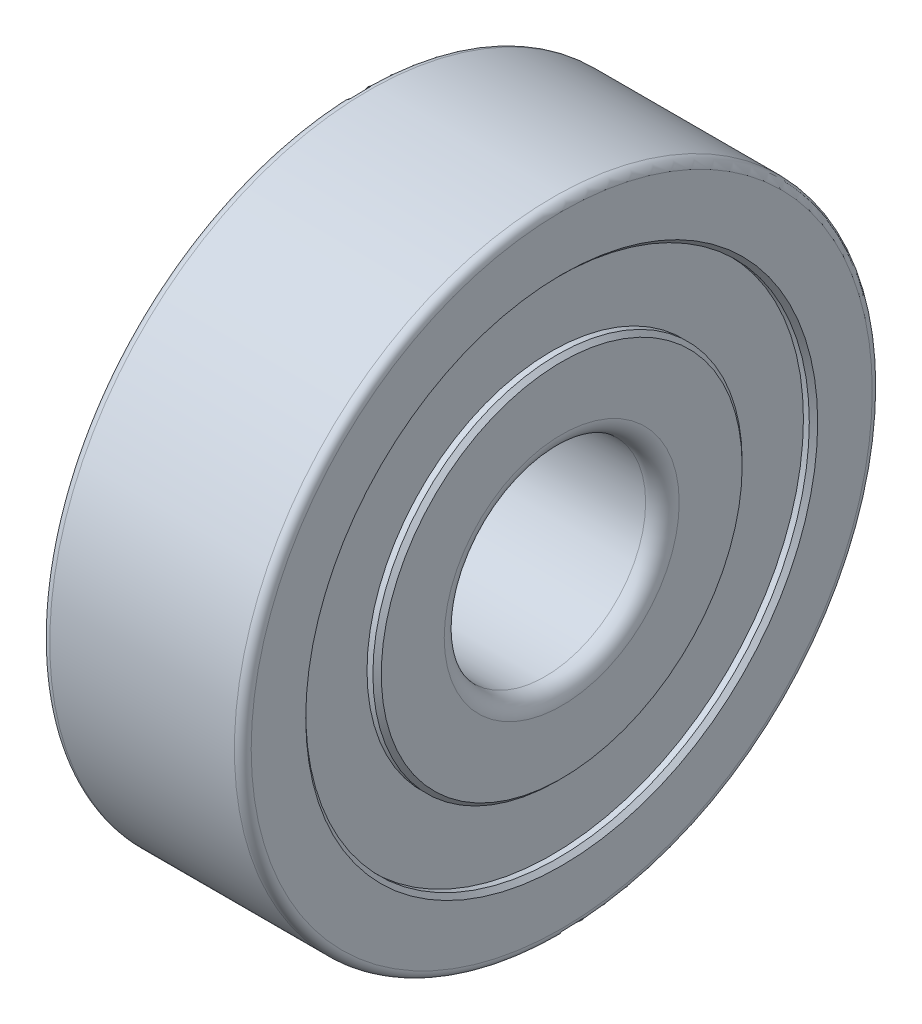
from build123d import *

# Parameters (mm, degrees)
CIRPATTERN2_COUNT = 8
SKETCH7_R         = 7.5
SKETCH7_R_2       = 5.5
SEAL_1_DEPTH      = 0.2
SKETCH8_R         = 7.5
SKETCH8_R_2       = 5.5
SEAL_2_DEPTH      = 0.2


with BuildPart() as part:
    # Sketch1 → Revolve1 (revolve)
    with BuildSketch(Plane.XY):
        with BuildLine():
            Line((-5.875, 5.5), (-4.299038106, 5.5))
            ThreePointArc((-4.299038106, 5.5), (-3, 4.75), (-1.700961894, 5.5))
            Line((-1.700961894, 5.5), (-0.125, 5.5))
            Line((-0.125, 5.5), (0, 5.375))
            Line((0, 5.375), (0, 3.5))
            ThreePointArc((0, 3.5), (-0.146446609, 3.146446609), (-0.5, 3))
            Line((-0.5, 3), (-5.5, 3))
            ThreePointArc((-5.5, 3), (-5.853553391, 3.146446609), (-6, 3.5))
            Line((-6, 3.5), (-6, 5.375))
            Line((-6, 5.375), (-5.875, 5.5))
        make_face()
        with BuildLine():
            Line((-0.25, 9.5), (-5.75, 9.5))
            ThreePointArc((-5.75, 9.5), (-5.926776695, 9.426776695), (-6, 9.25))
            Line((-6, 9.25), (-6, 7.625))
            Line((-6, 7.625), (-5.875, 7.5))
            Line((-5.875, 7.5), (-3.829156198, 7.5))
            ThreePointArc((-3.829156198, 7.5), (-3, 7.75), (-2.170843802, 7.5))
            Line((-2.170843802, 7.5), (-0.125, 7.5))
            Line((-0.125, 7.5), (0, 7.625))
            Line((0, 7.625), (0, 9.25))
            ThreePointArc((0, 9.25), (-0.073223305, 9.426776695), (-0.25, 9.5))
        make_face()
    revolve(axis=Axis((0, 0, 0), (-1, 0, 0)))

    # Sketch7 → Seal 1 (add)
    with BuildSketch(Plane(origin=(-0.5, 0, 0), x_dir=(0, 0, -1), z_dir=(1, 0, 0))):
        Circle(SKETCH7_R)
        Circle(SKETCH7_R_2, mode=Mode.SUBTRACT)
    extrude(amount=SEAL_1_DEPTH)

    # Sketch8 → Seal 2 (add)
    with BuildSketch(Plane.ZY.offset(5.5)):
        Circle(SKETCH8_R)
        Circle(SKETCH8_R_2, mode=Mode.SUBTRACT)
    extrude(amount=SEAL_2_DEPTH)


with BuildPart() as body_2:
    # Sketch2 → Revolve2 (revolve)
    with BuildSketch(Plane.XY):
        with BuildLine():
            Line((-3, 7.75), (-3, 4.75))
            ThreePointArc((-3, 4.75), (-1.5, 6.25), (-3, 7.75))
        make_face()
    revolve(axis=Axis((-3, 7.75, 0), (0, -1, 0)))


with BuildPart() as cirpattern2_1:
    # CirPattern2: pattern copy
    add(body_2.part.rotate(Axis((0, 0, 0), (1, 0, 0)), 1 * 360 / CIRPATTERN2_COUNT))


with BuildPart() as cirpattern2_2:
    # CirPattern2: pattern copy
    add(body_2.part.rotate(Axis((0, 0, 0), (1, 0, 0)), 2 * 360 / CIRPATTERN2_COUNT))


with BuildPart() as cirpattern2_3:
    # CirPattern2: pattern copy
    add(body_2.part.rotate(Axis((0, 0, 0), (1, 0, 0)), 3 * 360 / CIRPATTERN2_COUNT))


with BuildPart() as cirpattern2_4:
    # CirPattern2: pattern copy
    add(body_2.part.rotate(Axis((0, 0, 0), (1, 0, 0)), 4 * 360 / CIRPATTERN2_COUNT))


with BuildPart() as cirpattern2_5:
    # CirPattern2: pattern copy
    add(body_2.part.rotate(Axis((0, 0, 0), (1, 0, 0)), 5 * 360 / CIRPATTERN2_COUNT))


with BuildPart() as cirpattern2_6:
    # CirPattern2: pattern copy
    add(body_2.part.rotate(Axis((0, 0, 0), (1, 0, 0)), 6 * 360 / CIRPATTERN2_COUNT))


with BuildPart() as cirpattern2_7:
    # CirPattern2: pattern copy
    add(body_2.part.rotate(Axis((0, 0, 0), (1, 0, 0)), 7 * 360 / CIRPATTERN2_COUNT))


solid = Compound([part.part, body_2.part, cirpattern2_1.part, cirpattern2_2.part, cirpattern2_3.part, cirpattern2_4.part, cirpattern2_5.part, cirpattern2_6.part, cirpattern2_7.part])
